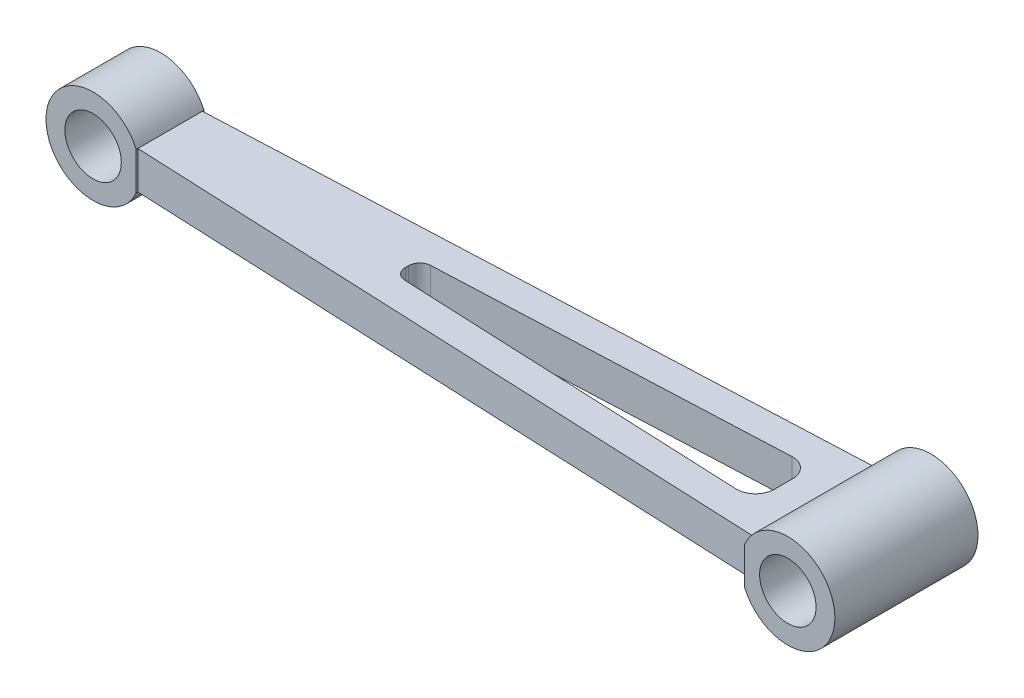
from build123d import *

# Parameters (mm, degrees)
SKETCH1_R               = 7.5
BOSS_EXTRUDE1_DEPTH     = 38
SKETCH2_W               = 23.956439237
SKETCH2_H               = 10
CUT_EXTRUDE1_DEPTH      = 8.5
CUT_EXTRUDE1_DEPTH_BACK = 18.5
FILLET1_R               = 3
FILLET2_R               = 5


with BuildPart() as part:
    # Sketch1 → Boss-Extrude1 (new body)
    with BuildSketch(Plane.XY):
        with BuildLine():
            Line((183.043560763, 5), (11.456439237, 5))
            ThreePointArc((11.456439237, 5), (-12.5, 0), (11.456439237, -5))
            Line((11.456439237, -5), (183.043560763, -5))
            ThreePointArc((183.043560763, -5), (207, 0), (183.043560763, 5))
        make_face()
        Circle(SKETCH1_R, mode=Mode.SUBTRACT)
        with Locations((194.5, 0)):
            Circle(SKETCH1_R, mode=Mode.SUBTRACT)
    extrude(amount=BOSS_EXTRUDE1_DEPTH)

    # Sketch2 → Cut-Extrude1 (cut, two sides)
    with BuildSketch(Plane(origin=(0, 5, 0), x_dir=(1, 0, 0), z_dir=(0, 1, 0))) as cut_extrude1_sk:
        Polygon((11.456439237, -27.558152076), (11.456439237, -28), (11.456439237, -38), (183.043560763, -38), (183.043560763, -35.049807592), align=None)
        with Locations((-0.521780381, -33)):
            Rectangle(SKETCH2_W, SKETCH2_H)
        with Locations((-0.521780381, -5)):
            Rectangle(SKETCH2_W, SKETCH2_H)
        Polygon((183.043560763, 0), (11.456439237, 0), (11.456439237, -10), (11.456439237, -10.441847924), (183.043560763, -2.950192408), align=None)
        Polygon((74.351780381, -15.703399507), (74.351780381, -22.296600493), (174.351780381, -26.662694784), (174.351780381, -11.337305216), align=None)
    extrude(amount=CUT_EXTRUDE1_DEPTH, mode=Mode.SUBTRACT)
    extrude(cut_extrude1_sk.sketch, amount=-CUT_EXTRUDE1_DEPTH_BACK, mode=Mode.SUBTRACT)

    # Fillet1
    fillet1_edges = [part.edges().sort_by_distance(p)[0] for p in [
        (74.351780381, 0, 22.296600493),
        (74.351780381, 0, 15.703399507),
    ]]
    fillet(fillet1_edges, radius=FILLET1_R)

    # Fillet2
    fillet2_edges = [part.edges().sort_by_distance(p)[0] for p in [
        (174.351780381, 0, 11.337305216),
        (174.351780381, 0, 26.662694784),
    ]]
    fillet(fillet2_edges, radius=FILLET2_R)


solid = part.part
